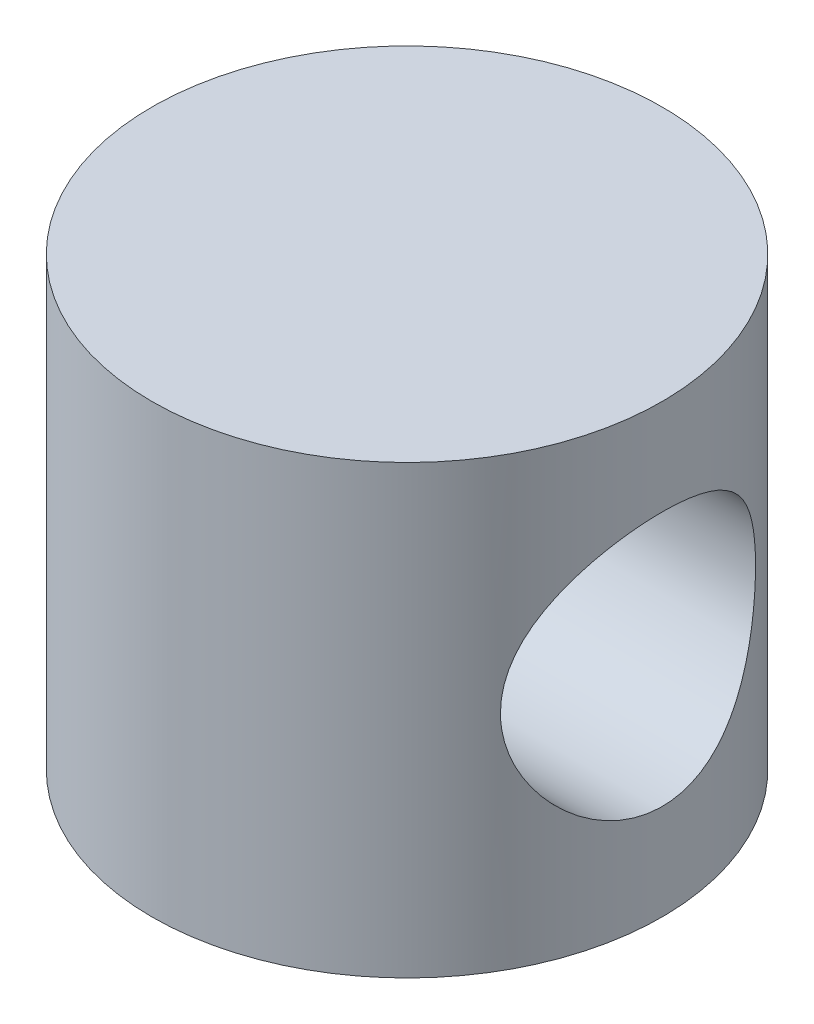
from build123d import *

# Parameters (mm, degrees)
SKETCH1_R           = 8
BOSS_EXTRUDE1_DEPTH = 14
SKETCH2_W           = 16
SKETCH2_H           = 17.069791858
BOSS_EXTRUDE2_DEPTH = 7
SKETCH3_R           = 4
CUT_EXTRUDE1_DEPTH  = 29
SKETCH4_W           = 17.069791858
SKETCH4_H           = 7
CUT_EXTRUDE2_DEPTH  = 29


with BuildPart() as part:
    # Sketch1 → Boss-Extrude1 (new body)
    with BuildSketch(Plane(origin=(0, 0, 0), x_dir=(1, 0, 0), z_dir=(0, 1, 0))):
        Circle(SKETCH1_R)
    extrude(amount=BOSS_EXTRUDE1_DEPTH)

    # Sketch2 → Boss-Extrude2 (add)
    with BuildSketch(Plane(origin=(0, 14, 0), x_dir=(1, 0, 0), z_dir=(0, 1, 0))):
        Rectangle(SKETCH2_W, SKETCH2_H)
    extrude(amount=BOSS_EXTRUDE2_DEPTH)

    # Sketch3 → Cut-Extrude1 (cut)
    with BuildSketch(Plane.ZY.offset(8)):
        with Locations((0, 7)):
            Circle(SKETCH3_R)
    extrude(amount=-CUT_EXTRUDE1_DEPTH, mode=Mode.SUBTRACT)

    # Sketch4 → Cut-Extrude2 (cut)
    with BuildSketch(Plane.ZY.offset(8)):
        with Locations((0, 17.5)):
            Rectangle(SKETCH4_W, SKETCH4_H)
    extrude(amount=-CUT_EXTRUDE2_DEPTH, mode=Mode.SUBTRACT)


solid = part.part
